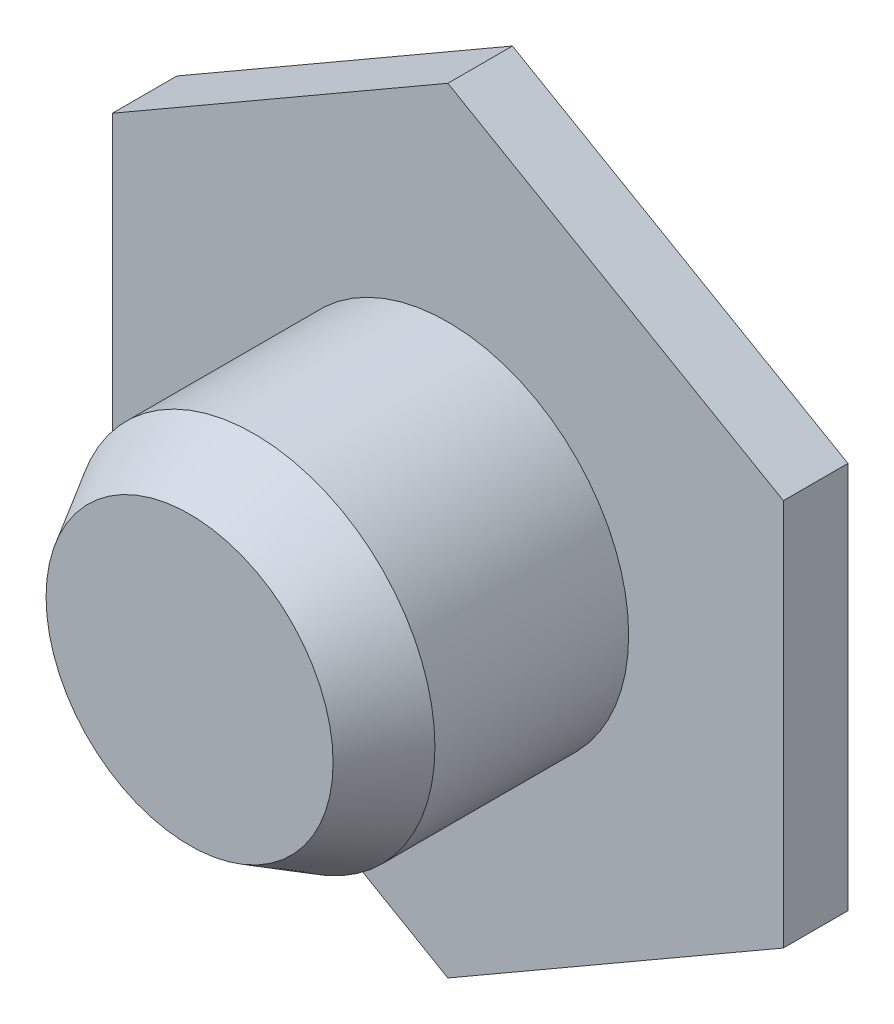
from build123d import *

# Parameters (mm, degrees)
BOSS_EXTRUDE1_DEPTH = 0.5
SKETCH2_R           = 1.4
BOSS_EXTRUDE2_DEPTH = 1.5
SKETCH3_R           = 1.4
BOSS_EXTRUDE3_DEPTH = 0.5
BOSS_EXTRUDE3_TAPER = 30


with BuildPart() as part:
    # Sketch1 → Boss-Extrude1 (new body)
    with BuildSketch(Plane.XY):
        Polygon((0, 3), (-2.598076211, 1.5), (-2.598076211, -1.5), (0, -3), (2.598076211, -1.5), (2.598076211, 1.5), align=None)
    extrude(amount=BOSS_EXTRUDE1_DEPTH)

    # Sketch2 → Boss-Extrude2 (add)
    with BuildSketch(Plane.XY.offset(0.5)):
        Circle(SKETCH2_R)
    extrude(amount=BOSS_EXTRUDE2_DEPTH)

    # Sketch3 → Boss-Extrude3 (add)
    with BuildSketch(Plane.XY.offset(2)):
        Circle(SKETCH3_R)
    extrude(amount=BOSS_EXTRUDE3_DEPTH, taper=BOSS_EXTRUDE3_TAPER)


solid = part.part
